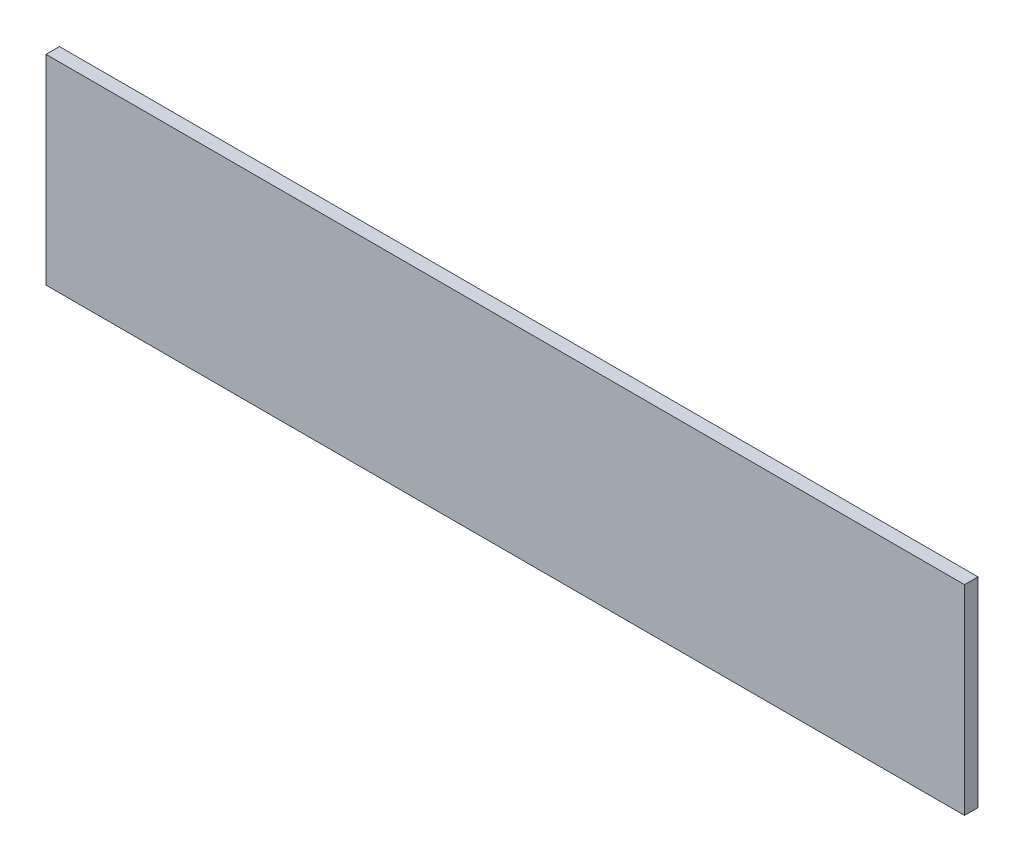
from build123d import *

# Parameters (mm, degrees)
ESQUISSE1_W        = 204.5
ESQUISSE1_H        = 44.5
BOSS_EXTRU_1_DEPTH = 3


with BuildPart() as part:
    # Esquisse1 → Boss.-Extru.1 (new body)
    with BuildSketch(Plane.XY):
        with Locations((121.732849384, -659.15036528)):
            Rectangle(ESQUISSE1_W, ESQUISSE1_H)
    extrude(amount=BOSS_EXTRU_1_DEPTH)


solid = part.part
